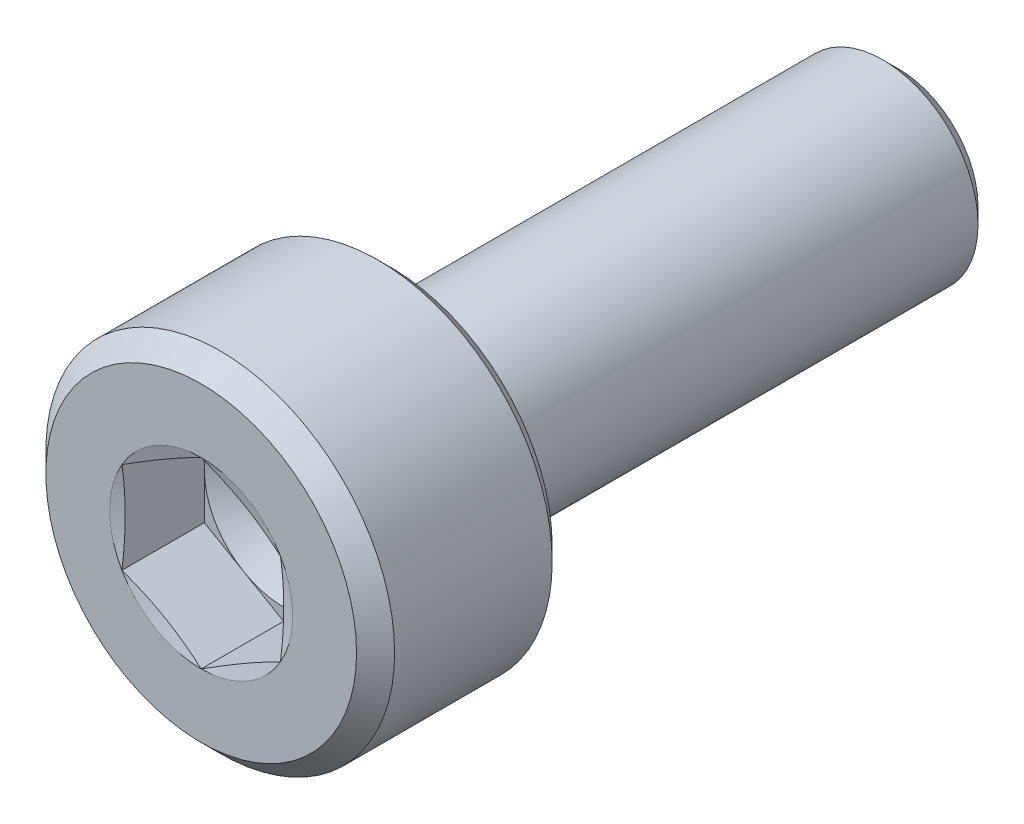
from build123d import *

# Parameters (mm, degrees)
CUT_EXTRUDE1_DEPTH = 1.3


with BuildPart() as part:
    # Sketch1 → Revolve1 (revolve)
    with BuildSketch(Plane(origin=(0, 0, 0), x_dir=(0, 0, -1), z_dir=(1, 0, 0))):
        with BuildLine():
            Line((0, 0), (0, 2.45))
            Line((0, 2.45), (0.3, 2.75))
            Line((0.3, 2.75), (2.785, 2.75))
            Line((2.785, 2.75), (3, 2.535))
            Line((3, 2.535), (3, 1.8))
            ThreePointArc((3, 1.8), (3.015193643, 1.74701055), (3.056157637, 1.710123155))
            Line((3.056157637, 1.710123155), (3.466157637, 1.510123155))
            ThreePointArc((3.466157637, 1.510123155), (3.48750205, 1.50256365), (3.51, 1.5))
            Line((3.51, 1.5), (10.75, 1.5))
            Line((10.75, 1.5), (11, 1.25))
            Line((11, 1.25), (11, 0))
            Line((11, 0), (0, 0))
        make_face()
    revolve(axis=Axis((0, 0, 0), (0, 0, -1)))

    # Sketch2 → Cut-Extrude1 (cut)
    with BuildSketch(Plane.XY):
        Polygon((0, 1.443375673), (-1.25, 0.721687836), (-1.25, -0.721687836), (0, -1.443375673), (1.25, -0.721687836), (1.25, 0.721687836), align=None)
    extrude(amount=-CUT_EXTRUDE1_DEPTH, mode=Mode.SUBTRACT)

    # Sketch3 → Cut-Revolve2 (revolve, cut)
    with BuildSketch(Plane(origin=(0, 0, 0), x_dir=(0, 0, -1), z_dir=(1, 0, 0))):
        Polygon((1.3, 0), (1.3, 1.25), (2.021687836, 0), align=None)
    revolve(axis=Axis((0, 0, -1.3), (0, 0, -1)), mode=Mode.SUBTRACT)

    # Sketch4 → Cut-Revolve3 (revolve, cut)
    with BuildSketch(Plane(origin=(0, 0, 0), x_dir=(0, 0, -1), z_dir=(1, 0, 0))):
        Polygon((0, 1.443375673), (0, 1.25), (0.051814855, 1.25), align=None)
    revolve(axis=Axis((0, 0, 0), (0, 0, -1)), mode=Mode.SUBTRACT)


solid = part.part
